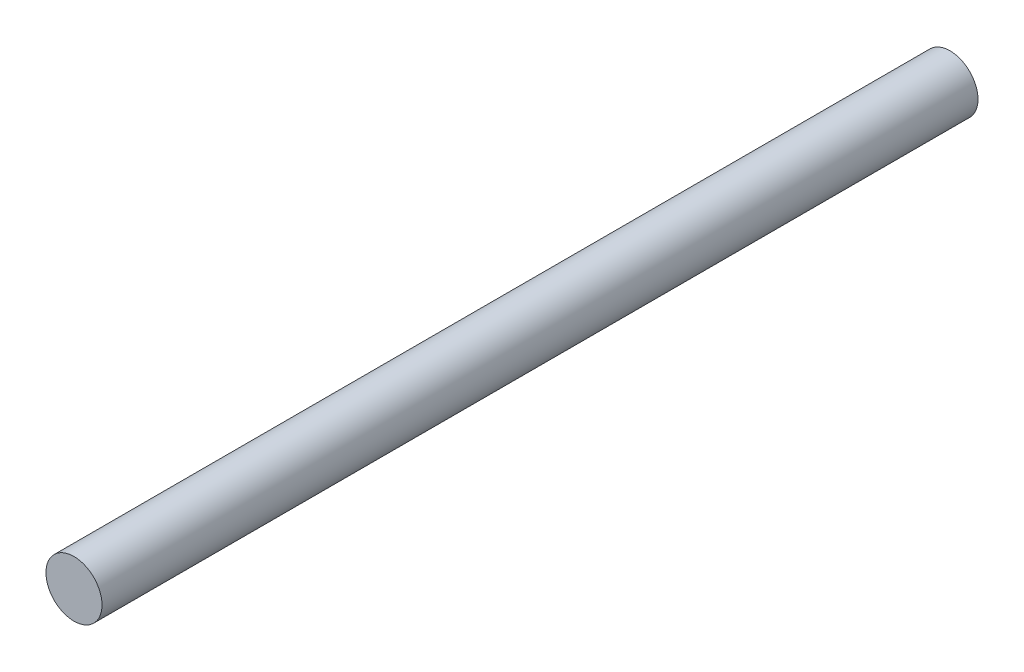
from build123d import *

# Parameters (mm, degrees)
IZIM1_R                     = 8
Y_KSEKLIK_EKSTR_ZYON1_DEPTH = 250


with BuildPart() as part:
    # Çizim1 → Yükseklik-Ekstrüzyon1 (new body)
    with BuildSketch(Plane.XY):
        Circle(IZIM1_R)
    extrude(amount=Y_KSEKLIK_EKSTR_ZYON1_DEPTH)


solid = part.part
